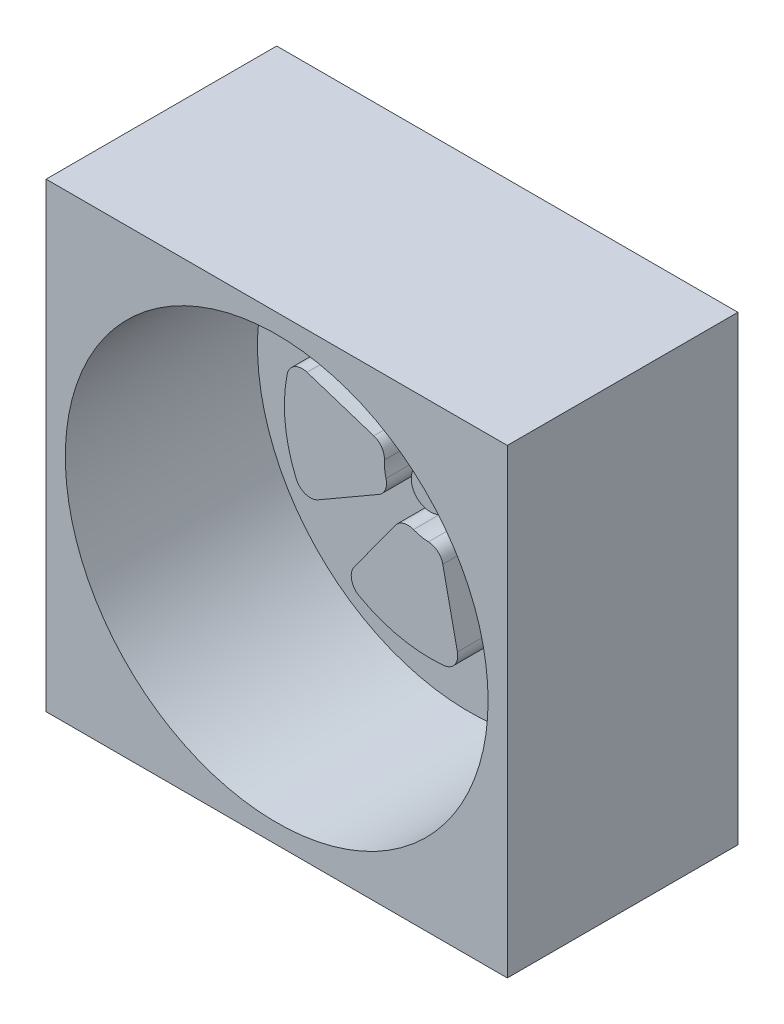
from build123d import *

# Parameters (mm, degrees)
CROQUIS1_R              = 30
SALIENTE_EXTRUIR1_DEPTH = 30
CROQUIS2_R              = 27.5
CORTAR_EXTRUIR1_DEPTH   = 25
CROQUIS3_R              = 2.5
SALIENTE_EXTRUIR2_DEPTH = 5
CROQUIS4_R              = 5.5
CROQUIS4_R_2            = 2.5
CORTAR_EXTRUIR2_DEPTH   = 2
CROQUIS6_W              = 60
CROQUIS6_H              = 60
CROQUIS6_R              = 27.5
SALIENTE_EXTRUIR3_DEPTH = 30
SALIENTE_EXTRUIR5_DEPTH = 5
REDONDEO1_R             = 2


with BuildPart() as part:
    # Croquis1 → Saliente-Extruir1 (new body)
    with BuildSketch(Plane.XY):
        Circle(CROQUIS1_R)
    extrude(amount=SALIENTE_EXTRUIR1_DEPTH)

    # Croquis2 → Cortar-Extruir1 (cut)
    with BuildSketch(Plane.XY.offset(30)):
        Circle(CROQUIS2_R)
    extrude(amount=-CORTAR_EXTRUIR1_DEPTH, mode=Mode.SUBTRACT)

    # Croquis3 → Saliente-Extruir2 (add)
    with BuildSketch(Plane.XY.offset(5)):
        Circle(CROQUIS3_R)
    extrude(amount=SALIENTE_EXTRUIR2_DEPTH)

    # Croquis4 → Cortar-Extruir2 (cut)
    with BuildSketch(Plane.XY.offset(5)):
        Circle(CROQUIS4_R)
        Circle(CROQUIS4_R_2, mode=Mode.SUBTRACT)
    extrude(amount=-CORTAR_EXTRUIR2_DEPTH, mode=Mode.SUBTRACT)

    # Croquis6 → Saliente-Extruir3 (add)
    with BuildSketch(Plane.XY.offset(30)):
        Rectangle(CROQUIS6_W, CROQUIS6_H)
        Circle(CROQUIS6_R, mode=Mode.SUBTRACT)
    extrude(amount=-SALIENTE_EXTRUIR3_DEPTH)

    # Croquis7 → Saliente-Extruir5 (add)
    with BuildSketch(Plane.XY.offset(5)):
        with BuildLine():
            Line((0, 6), (0, 19))
            ThreePointArc((0, 19), (-7.727996218, 17.357363695), (-14.119751684, 12.713481521))
            Line((-14.119751684, 12.713481521), (-4.458868953, 4.014783638))
            ThreePointArc((-4.458868953, 4.014783638), (-2.440419858, 5.481272746), (0, 6))
        make_face()
        with BuildLine():
            Line((2.440419858, 5.481272746), (7.727996218, 17.357363695))
            ThreePointArc((7.727996218, 17.357363695), (14.119751684, 12.713481521), (18.07007381, 5.871322893))
            Line((18.07007381, 5.871322893), (5.706339098, 1.854101966))
            ThreePointArc((5.706339098, 1.854101966), (4.458868953, 4.014783638), (2.440419858, 5.481272746))
        make_face()
        with BuildLine():
            Line((5.967131372, -0.62717078), (18.895916012, -1.986040802))
            ThreePointArc((18.895916012, -1.986040802), (16.454482672, -9.5), (11.167919794, -15.371322893))
            Line((11.167919794, -15.371322893), (3.526711514, -4.854101966))
            ThreePointArc((3.526711514, -4.854101966), (5.196152423, -3), (5.967131372, -0.62717078))
        make_face()
        with BuildLine():
            Line((1.247470145, -5.868885604), (3.950322126, -18.584804414))
            ThreePointArc((3.950322126, -18.584804414), (-3.950322126, -18.584804414), (-11.167919794, -15.371322893))
            Line((-11.167919794, -15.371322893), (-3.526711514, -4.854101966))
            ThreePointArc((-3.526711514, -4.854101966), (-1.247470145, -5.868885604), (1.247470145, -5.868885604))
        make_face()
        with BuildLine():
            Line((-5.196152423, -3), (-16.454482672, -9.5))
            ThreePointArc((-16.454482672, -9.5), (-18.895916012, -1.986040802), (-18.07007381, 5.871322893))
            Line((-18.07007381, 5.871322893), (-5.706339098, 1.854101966))
            ThreePointArc((-5.706339098, 1.854101966), (-5.967131372, -0.62717078), (-5.196152423, -3))
        make_face()
    extrude(amount=SALIENTE_EXTRUIR5_DEPTH)

    # Redondeo1
    redondeo1_edges = [part.edges().sort_by_distance(p)[0] for p in [
        (-4.458868953, 4.014783638, 7.5),
        (0, 6, 7.5),
        (0, 19, 7.5),
        (-14.119751684, 12.713481521, 7.5),
        (2.440419858, 5.481272746, 7.5),
        (5.706339098, 1.854101966, 7.5),
        (18.07007381, 5.871322893, 7.5),
        (7.727996218, 17.357363695, 7.5),
        (5.967131372, -0.62717078, 7.5),
        (3.526711514, -4.854101966, 7.5),
        (11.167919794, -15.371322893, 7.5),
        (18.895916012, -1.986040802, 7.5),
        (1.247470145, -5.868885604, 7.5),
        (-3.526711514, -4.854101966, 7.5),
        (-11.167919794, -15.371322893, 7.5),
        (3.950322126, -18.584804414, 7.5),
        (-5.196152423, -3, 7.5),
        (-5.706339098, 1.854101966, 7.5),
        (-18.07007381, 5.871322893, 7.5),
        (-16.454482672, -9.5, 7.5),
    ]]
    fillet(redondeo1_edges, radius=REDONDEO1_R)


solid = part.part
